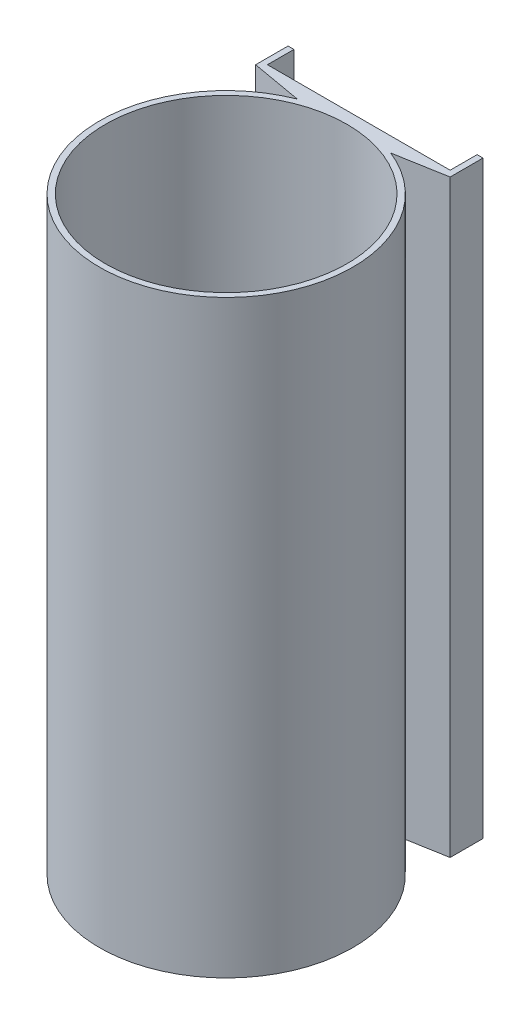
from build123d import *

# Parameters (mm, degrees)
SKETCH3_R           = 43
SKETCH3_R_2         = 41
BOSS_EXTRUDE1_DEPTH = 200


with BuildPart() as part:
    # Sketch3 → Boss-Extrude1 (new body)
    with BuildSketch(Plane(origin=(0, 0, 0), x_dir=(1, 0, 0), z_dir=(0, 1, 0))):
        with BuildLine():
            Line((15.84339478, 39.974827602), (33, 43))
            Line((33, 43), (33, 54.159072389))
            Line((33, 54.159072389), (31, 54.159072389))
            Line((31, 54.159072389), (31, 45))
            Line((31, 45), (-31, 45))
            Line((-31, 45), (-31, 54))
            Line((-31, 54), (-33, 54))
            Line((-33, 54), (-33, 43))
            Line((-33, 43), (-15.84339478, 39.974827602))
            ThreePointArc((-15.84339478, 39.974827602), (0, 43), (15.84339478, 39.974827602))
        make_face()
        Circle(SKETCH3_R)
        Circle(SKETCH3_R_2, mode=Mode.SUBTRACT)
    extrude(amount=BOSS_EXTRUDE1_DEPTH)


solid = part.part
